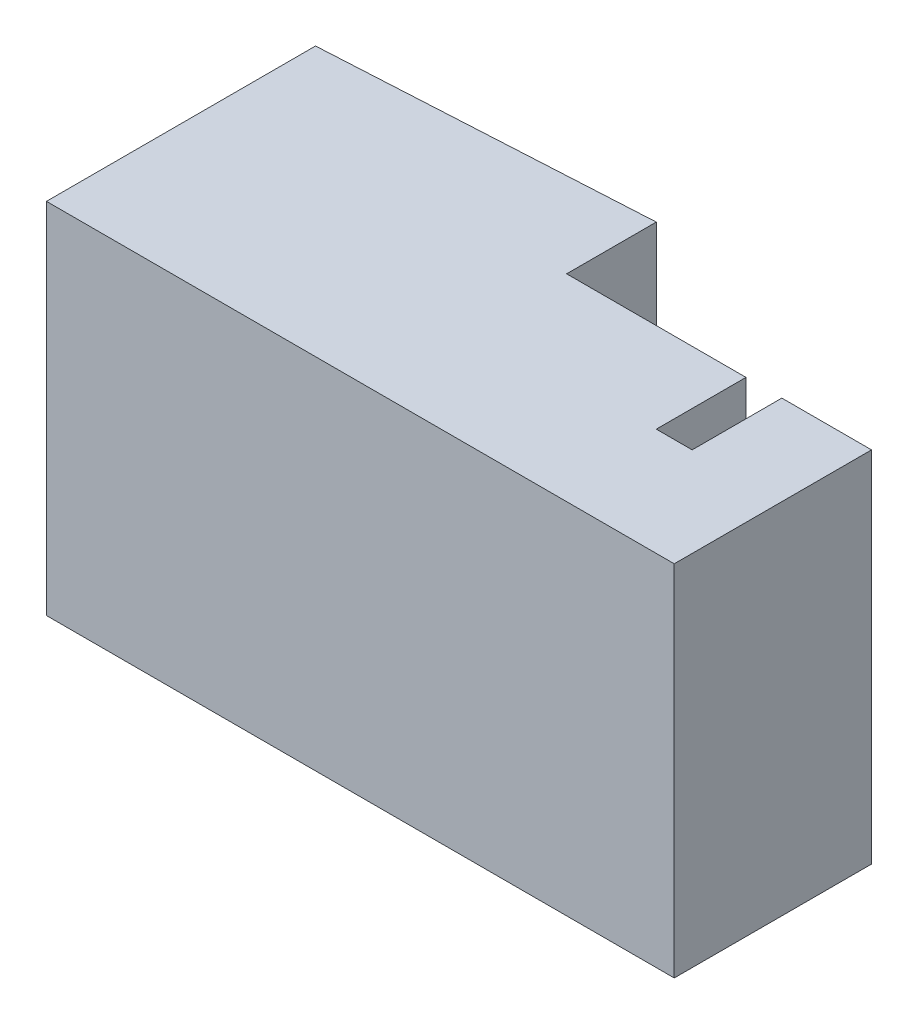
from build123d import *

# Parameters (mm, degrees)
BOSS_EXTRUDE1_DEPTH = 20


with BuildPart() as part:
    # Sketch1 → Boss-Extrude1 (new body)
    with BuildSketch(Plane(origin=(0, 0, 0), x_dir=(1, 0, 0), z_dir=(0, 1, 0))):
        Polygon((0, 0), (35, 0), (35, 11), (30, 11), (30, 6), (28, 6), (28, 11), (18, 11), (18, 16), (0, 15), align=None)
    extrude(amount=BOSS_EXTRUDE1_DEPTH)


solid = part.part
